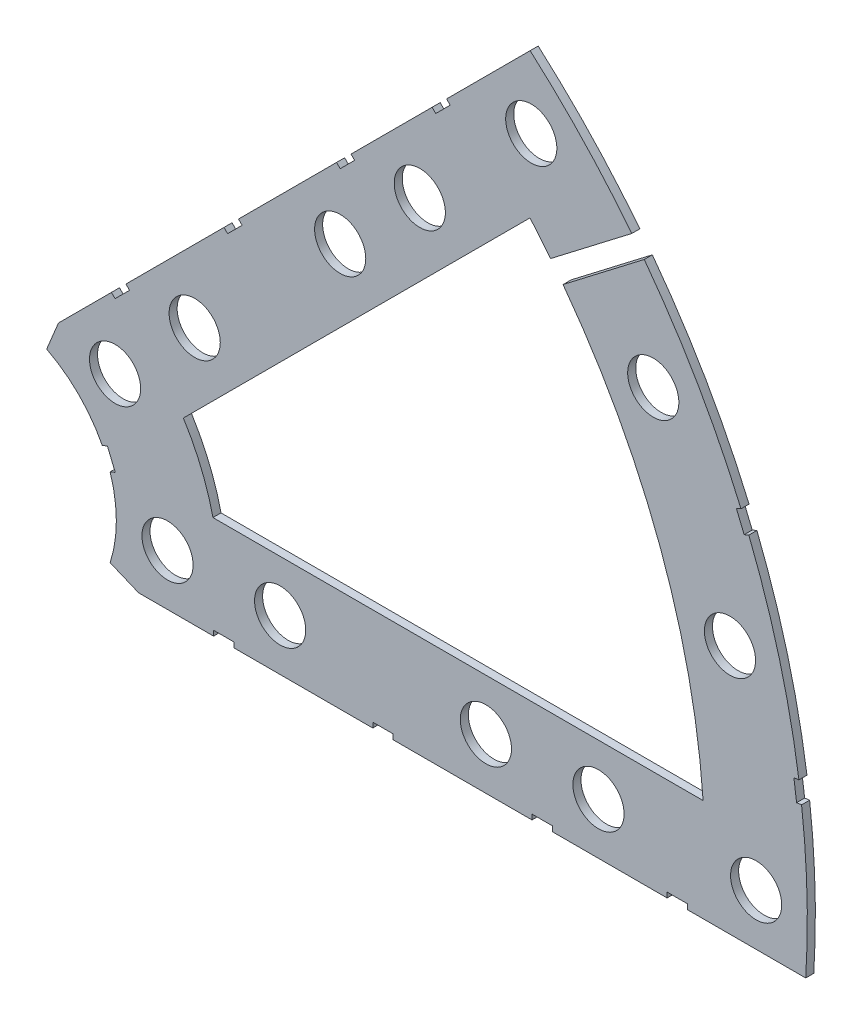
from build123d import *

# Parameters (mm, degrees)
BOSS_EXTRUDE1_DEPTH = 1
SKETCH2_R           = 3.175
CUT_EXTRUDE1_DEPTH  = 2
SKETCH3_W           = 2.54
SKETCH3_H           = 0.635
CUT_EXTRUDE2_DEPTH  = 2


with BuildPart() as part:
    # Sketch1 → Boss-Extrude1 (new body)
    with BuildSketch(Plane.XY):
        with BuildLine():
            Line((67.21146711, 76.191723231), (8.696654013, 17.676910134))
            Line((8.696654013, 17.676910134), (7.228954972, 14.133571205))
            ThreePointArc((7.228954972, 14.133571205), (14.666587579, 6.075099489), (15.105587123, -4.88230096))
            Line((15.105587123, -4.88230096), (18.648926052, -6.35))
            Line((18.648926052, -6.35), (101.401368334, -6.35))
            ThreePointArc((101.401368334, -6.35), (93.866160503, 38.880636728), (67.21146711, 76.191723231))
        make_face()
        with BuildLine():
            Line((88.672924278, 6.35), (27.86051193, 6.35))
            ThreePointArc((27.86051193, 6.35), (26.399857642, 10.93517908), (24.190484974, 15.210228852))
            Line((24.190484974, 15.210228852), (67.191354125, 58.211098004))
            ThreePointArc((67.191354125, 58.211098004), (82.13289044, 34.020557137), (88.672924278, 6.35))
        make_face(mode=Mode.SUBTRACT)
    extrude(amount=BOSS_EXTRUDE1_DEPTH)

    # Sketch2 → Cut-Extrude1 (cut, through all)
    with BuildSketch(Plane.XY.offset(1)):
        with Locations((22.225, 0)):
            Circle(SKETCH2_R)
        with Locations((36.195, 0)):
            Circle(SKETCH2_R)
        with Locations((61.722, 0)):
            Circle(SKETCH2_R)
        with Locations((75.692, 0)):
            Circle(SKETCH2_R)
        with Locations((95.25, 0)):
            Circle(SKETCH2_R)
        with Locations((15.715448212, 15.715448212)):
            Circle(SKETCH2_R)
        with Locations((25.593729945, 25.593729945)):
            Circle(SKETCH2_R)
        with Locations((43.644044748, 43.644044748)):
            Circle(SKETCH2_R)
        with Locations((53.522326482, 53.522326482)):
            Circle(SKETCH2_R)
        with Locations((92.004434954, 24.652514046)):
            Circle(SKETCH2_R)
        with Locations((82.48891971, 47.625)):
            Circle(SKETCH2_R)
        with Locations((67.351920908, 67.351920908)):
            Circle(SKETCH2_R)
    extrude(amount=-CUT_EXTRUDE1_DEPTH, mode=Mode.SUBTRACT)

    # Sketch3 → Cut-Extrude2 (cut, through all)
    with BuildSketch(Plane.XY.offset(1)):
        Polygon((15.266435406, 24.246691527), (17.06248663, 26.042742751), (17.511499436, 25.593729945), (15.715448212, 23.797678721), align=None)
        Polygon((44.991083167, 53.971339288), (43.195031942, 52.175288063), (43.644044748, 51.726275257), (45.440095973, 53.522326482), align=None)
        with Locations((29.21, -6.0325)):
            Rectangle(SKETCH3_W, SKETCH3_H)
        with Locations((68.707, -6.0325)):
            Rectangle(SKETCH3_W, SKETCH3_H)
        Polygon((29.230733674, 38.210989795), (31.026784898, 40.007041019), (31.475797704, 39.558028213), (29.67974648, 37.761976989), align=None)
        Polygon((56.845021246, 65.825277367), (55.048970022, 64.029226143), (55.497982828, 63.580213337), (57.294034052, 65.376264561), align=None)
        with Locations((48.9585, -6.0325)):
            Rectangle(SKETCH3_W, SKETCH3_H)
        with Locations((85.471, -6.0325)):
            Rectangle(SKETCH3_W, SKETCH3_H)
        Polygon((99.935462164, 14.437711971), (100.266998693, 11.919442024), (101.526133667, 12.085210288), (101.194597138, 14.603480236), align=None)
        Polygon((93.765504959, 37.464305742), (94.938831965, 37.950313702), (93.966816047, 40.296967714), (92.793489041, 39.810959755), align=None)
        Polygon((80.839131101, 63.630846944), (82.385385131, 61.61572946), (70.294680225, 52.338205282), (68.748426195, 54.353322766), align=None)
        Polygon((13.593916116, 7.005422516), (14.565932035, 4.658768503), (15.739259041, 5.144776462), (14.767243123, 7.491430475), align=None)
    extrude(amount=-CUT_EXTRUDE2_DEPTH, mode=Mode.SUBTRACT)


solid = part.part
